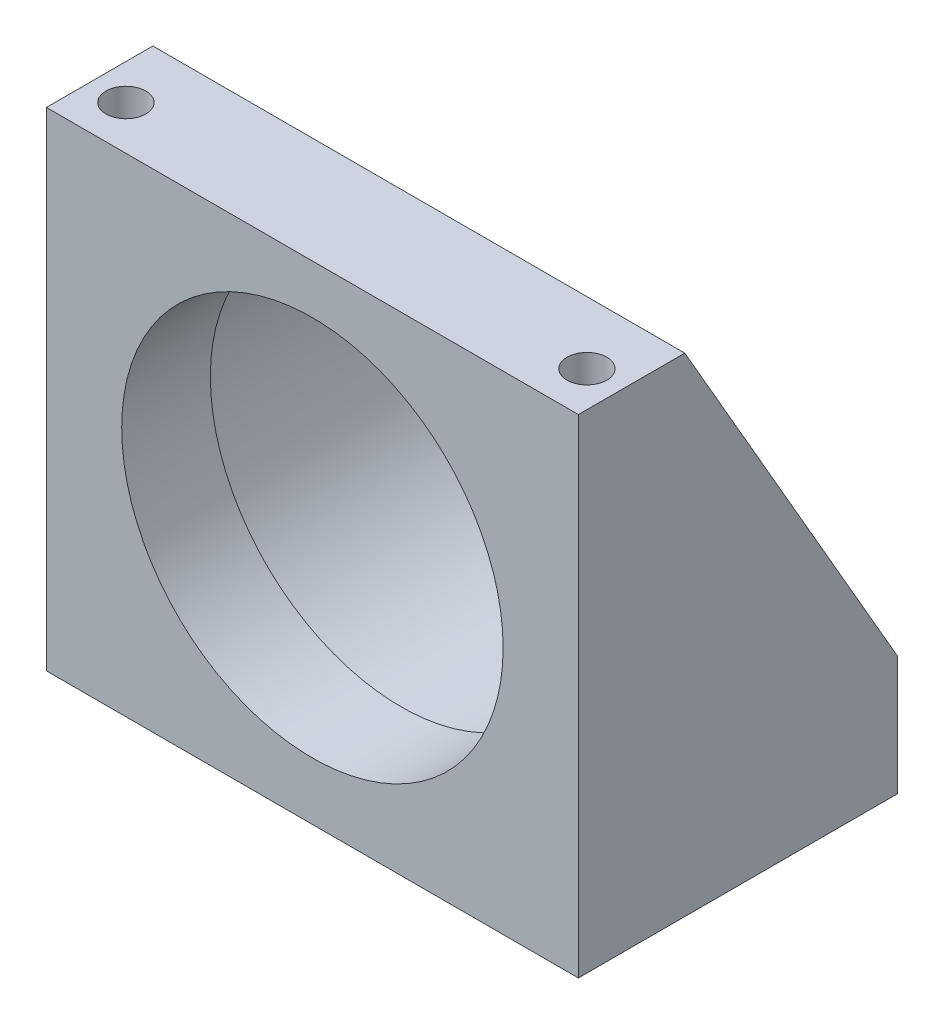
from build123d import *

# Parameters (mm, degrees)
SKETCH1_W          = 95.25
SKETCH1_H          = 87.376
SKETCH1_R          = 34.1503
EXTRUDE1_DEPTH     = 57.15
CUT_EXTRUDE1_DEPTH = 96.25
SKETCH3_R          = 36.576
CUT_EXTRUDE2_DEPTH = 41.275
FILLET1_R          = 1.524
HOLE1_D            = 7.1374
HOLE1_DEPTH        = 87.376


with BuildPart() as part:
    # Sketch1 → Extrude1 (new body)
    with BuildSketch(Plane.XY):
        with Locations((0, 43.688)):
            Rectangle(SKETCH1_W, SKETCH1_H)
        with Locations((0, 44.45)):
            Circle(SKETCH1_R, mode=Mode.SUBTRACT)
    extrude(amount=-EXTRUDE1_DEPTH)

    # Sketch2 → Cut-Extrude1 (cut, through all)
    with BuildSketch(Plane(origin=(47.625, 0, 0), x_dir=(0, 0, -1), z_dir=(1, 0, 0))):
        Polygon((19.05, 87.376), (57.15, 21.336), (57.15, 87.376), align=None)
    extrude(amount=-CUT_EXTRUDE1_DEPTH, mode=Mode.SUBTRACT)

    # Sketch3 → Cut-Extrude2 (cut)
    with BuildSketch(Plane(origin=(0, 0, -57.15), x_dir=(-1, 0, 0), z_dir=(0, 0, -1))):
        with Locations(Location((0, 44.45, 0), (0, 0, 320.806273741))):  # turned: the seam where the file's is
            Circle(SKETCH3_R)
    extrude(amount=-CUT_EXTRUDE2_DEPTH, mode=Mode.SUBTRACT)

    # Fillet1
    fillet1_edges = [part.edges().sort_by_distance(p)[0] for p in [
        (28.346900713, 67.564, -15.875),
    ]]
    fillet(fillet1_edges, radius=FILLET1_R)

    # Hole1
    with Locations(Plane(origin=(0, 87.376, 0), x_dir=(-1, 0, 0), z_dir=(0, 1, 0))):
        with Locations((41.275, -7.874), (-41.275, -7.874)):
            Hole(HOLE1_D / 2, depth=HOLE1_DEPTH)


solid = part.part
